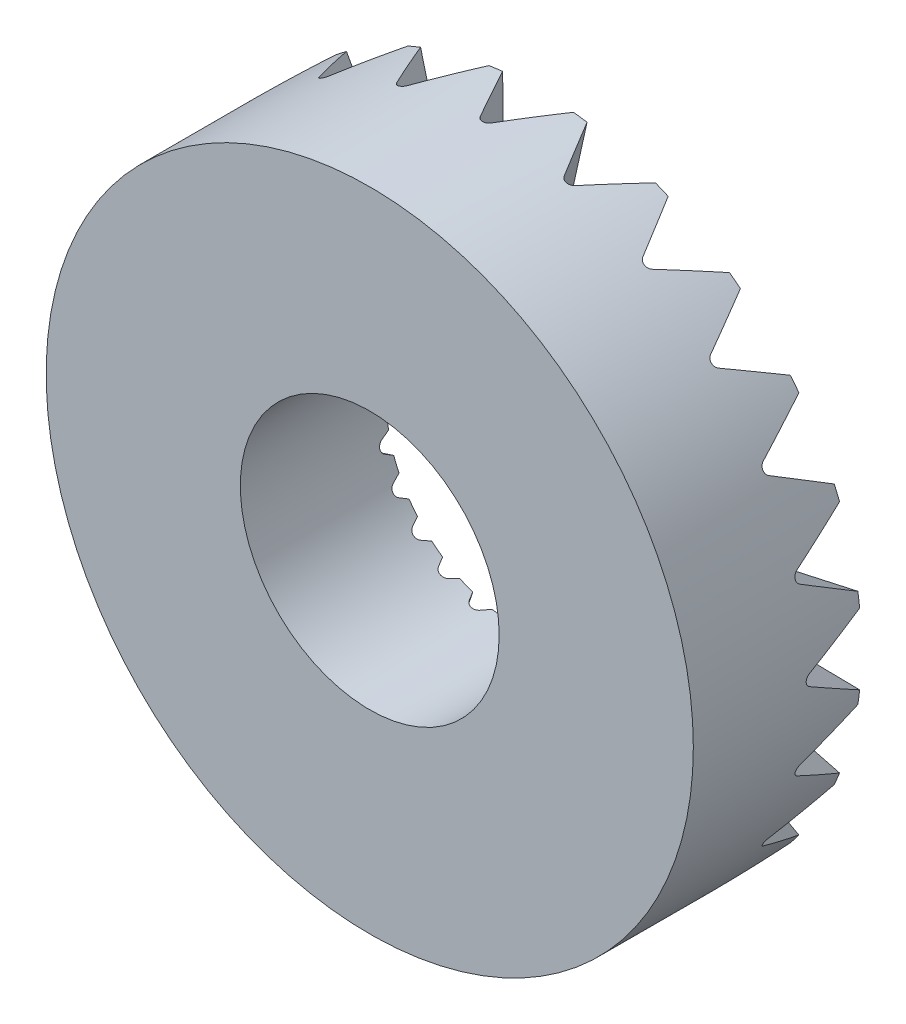
from build123d import *

# Parameters (mm, degrees)
SCHNITT_LINEAR_AUSTRAGEN1_DEPTH = 26.576407132
KREISMUSTER1_COUNT              = 24


with BuildPart() as part:
    # Skizze1 → Rotation1 (revolve)
    with BuildSketch(Plane(origin=(0, 0, 0), x_dir=(0, 0, -1), z_dir=(1, 0, 0)), mode=Mode.PRIVATE) as rotation1_sk:
        Polygon((0, 10), (0, 25), (13, 25), (11.285556945, 10), align=None)
    revolve(rotation1_sk.sketch.rotate(Axis((0, 0, 0), (0, 0, -1)), 90), axis=Axis((0, 0, 0), (0, 0, -1)))  # turned: the seam where the file's is

    # Skizze3 → Schnitt-Linear austragen1 (cut, through all)
    with BuildSketch(Plane(origin=(-0.73334518, 0, -0.08381857), x_dir=(0.113556878, 0, -0.993531497), z_dir=(0.993531497, 0, 0.113556878))):
        with BuildLine():
            Line((19.660254038, 5), (11.75, 0.433012702))
            ThreePointArc((11.75, 0.433012702), (11.5, 0), (11.75, -0.433012702))
            Line((11.75, -0.433012702), (19.660254038, -5))
            Line((19.660254038, -5), (19.660254038, 5))
        make_face()
    schnitt_linear_austragen1 = extrude(amount=SCHNITT_LINEAR_AUSTRAGEN1_DEPTH, mode=Mode.SUBTRACT)

    # Kreismuster1: Schnitt-Linear austragen1 ×24 about axis
    kreismuster1_axis = Axis((0, 0, 0), (0, 0, 1))
    for i in range(1, KREISMUSTER1_COUNT):
        add(schnitt_linear_austragen1.rotate(kreismuster1_axis, i * 360 / KREISMUSTER1_COUNT), mode=Mode.SUBTRACT)


solid = part.part
